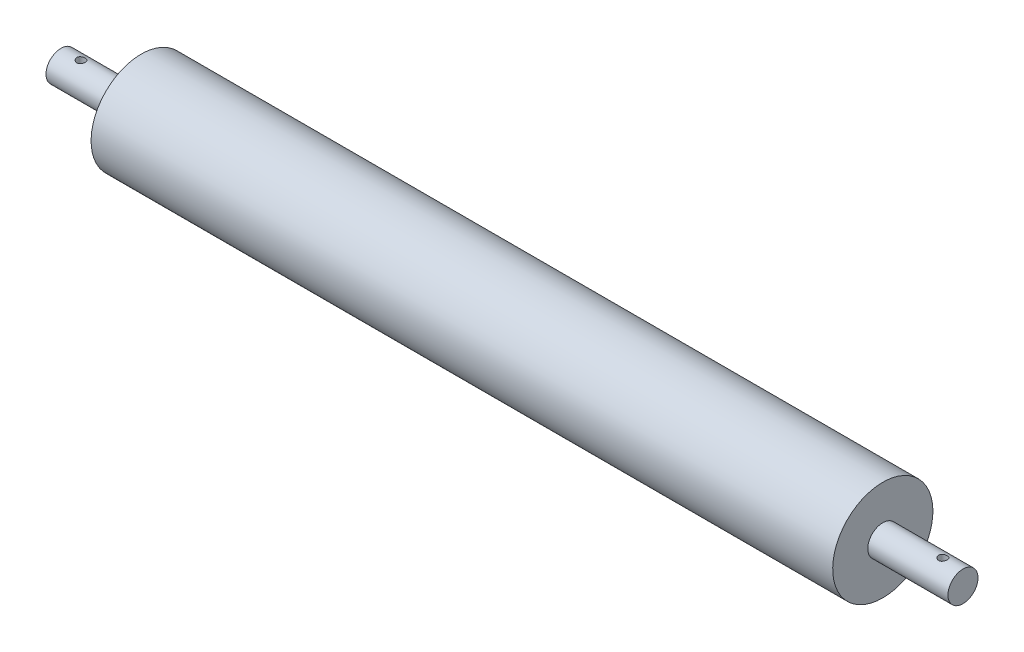
from build123d import *


with BuildPart() as part:
    # 草图1 → 旋转1 (revolve)
    with BuildSketch(Plane.XY):
        Polygon((-185, 25), (185, 25), (185, 7.5), (225, 7.5), (225, 0), (-225, 0), (-225, 7.5), (-185, 7.5), align=None)
    revolve(axis=Axis((-225, 0, 0), (1, 0, 0)))

    # 草图3 → M5 螺纹孔1 (revolve, cut)
    with BuildSketch(Plane(origin=(-215, -7.5, 0), x_dir=(0, 0, -1), z_dir=(1, 0, 0))):
        Polygon((0, 0), (0, 51.2618073), (2.1, 50), (2.1, 0), align=None)
    hole_wizard_m5_1 = revolve(axis=Axis((-215, -13.85, 0), (0, 1, 0)), mode=Mode.SUBTRACT)

    # 镜向1: M5 螺纹孔1 across plane
    add(hole_wizard_m5_1.mirror(Plane(origin=(0, 0, 0), x_dir=(0, 0, 1), z_dir=(1, 0, 0))), mode=Mode.SUBTRACT)


solid = part.part
